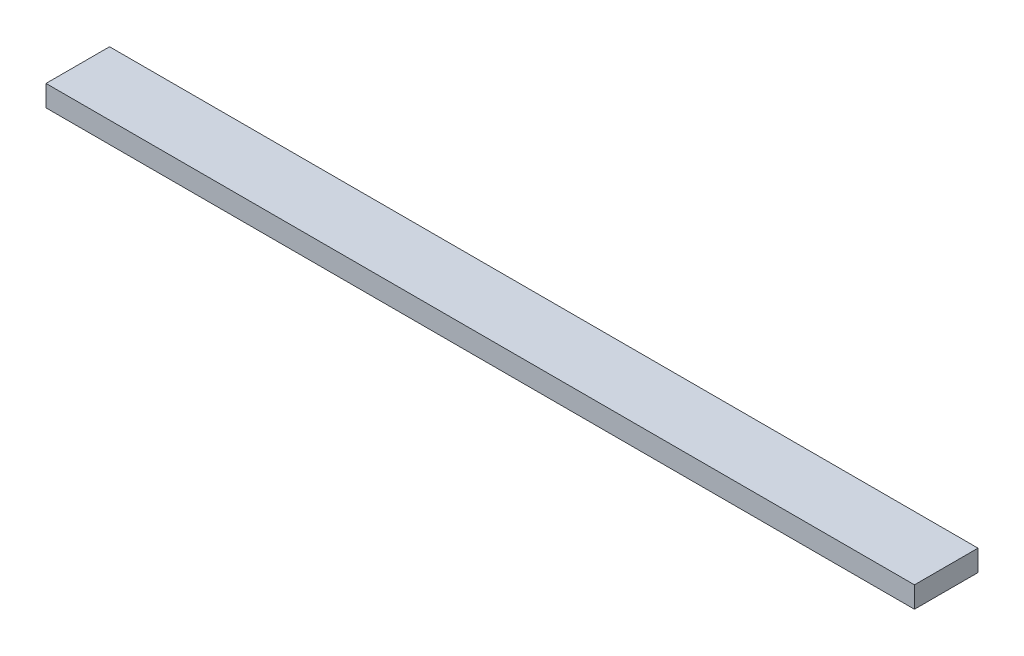
from build123d import *

# Parameters (mm, degrees)
SKETCH1_W           = 410
SKETCH1_H           = 30
BOSS_EXTRUDE1_DEPTH = 10


with BuildPart() as part:
    # Sketch1 → Boss-Extrude1 (new body)
    with BuildSketch(Plane(origin=(0, 0, 0), x_dir=(1, 0, 0), z_dir=(0, 1, 0))):
        Rectangle(SKETCH1_W, SKETCH1_H)
    extrude(amount=BOSS_EXTRUDE1_DEPTH)


solid = part.part
